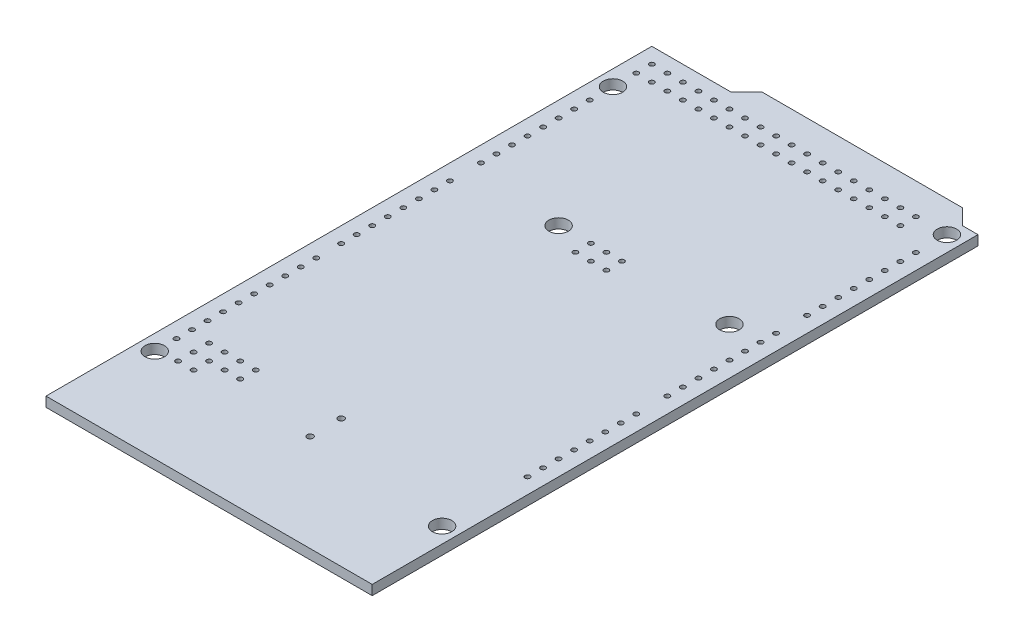
from build123d import *

# Parameters (mm, degrees)
SKETCH1_R           = 1.5875
BOSS_EXTRUDE1_DEPTH = 1.6
SKETCH2_R           = 0.4
CUT_EXTRUDE1_DEPTH  = 1.65
SKETCH3_R           = 0.4
CUT_EXTRUDE2_DEPTH  = 1.65
LPATTERN1_COUNT     = 26
LPATTERN1_PITCH     = 2.54
SKETCH4_R           = 0.4
CUT_EXTRUDE3_DEPTH  = 1.65
LPATTERN2_COUNT     = 10
LPATTERN2_PITCH     = 2.54
LPATTERN3_COUNT     = 17
LPATTERN3_PITCH     = 2.54
SKETCH5_R           = 0.4
SKETCH5_R_2         = 0.5
CUT_EXTRUDE4_DEPTH  = 10
SKETCH7_R           = 0.4
CUT_EXTRUDE6_DEPTH  = 10
LPATTERN4_COUNT     = 18
LPATTERN4_PITCH     = 2.54


with BuildPart() as part:
    # Sketch1 → Boss-Extrude1 (new body)
    with BuildSketch(Plane(origin=(0, 0, 0), x_dir=(1, 0, 0), z_dir=(0, 1, 0))):
        Polygon((0, 0), (-53.34, 0), (-53.34, 99.06), (-40.386, 99.06), (-37.846, 101.6), (-5.08, 101.6), (-2.54, 99.06), (0, 99.06), align=None)
        with Locations((-7.62, 66.04)):
            Circle(SKETCH1_R, mode=Mode.SUBTRACT)
        with Locations((-35.56, 66.04)):
            Circle(SKETCH1_R, mode=Mode.SUBTRACT)
        with Locations((-2.54, 13.97)):
            Circle(SKETCH1_R, mode=Mode.SUBTRACT)
        with Locations((-50.8, 15.24)):
            Circle(SKETCH1_R, mode=Mode.SUBTRACT)
        with Locations((-2.54, 96.52)):
            Circle(SKETCH1_R, mode=Mode.SUBTRACT)
        with Locations((-50.8, 90.17)):
            Circle(SKETCH1_R, mode=Mode.SUBTRACT)
    extrude(amount=-BOSS_EXTRUDE1_DEPTH)

    # Sketch2 → Cut-Extrude1 (cut)
    with BuildSketch(Plane(origin=(0, 0, 0), x_dir=(1, 0, 0), z_dir=(0, 1, 0))):
        with Locations((-2.54, 27.94)):
            Circle(SKETCH2_R)
    cut_extrude1 = extrude(amount=-CUT_EXTRUDE1_DEPTH, mode=Mode.SUBTRACT)

    # Sketch3 → Cut-Extrude2 (cut)
    with BuildSketch(Plane(origin=(0, 0, 0), x_dir=(1, 0, 0), z_dir=(0, 1, 0))):
        with Locations((-50.8, 18.796)):
            Circle(SKETCH3_R)
    cut_extrude2 = extrude(amount=-CUT_EXTRUDE2_DEPTH, mode=Mode.SUBTRACT)

    # LPattern1: Cut-Extrude1 ×26, 2 skipped
    with Locations(*[(0, 0, -i * LPATTERN1_PITCH) for i in range(1, LPATTERN1_COUNT) if i not in (8, 17)]):
        add(cut_extrude1, mode=Mode.SUBTRACT)

    # Sketch4 → Cut-Extrude3 (cut)
    with BuildSketch(Plane(origin=(0, 0, 0), x_dir=(1, 0, 0), z_dir=(0, 1, 0))):
        with Locations((-50.8, 45.72)):
            Circle(SKETCH4_R)
    cut_extrude3 = extrude(amount=-CUT_EXTRUDE3_DEPTH, mode=Mode.SUBTRACT)

    # LPattern2: Cut-Extrude2 ×10
    with Locations(*[(0, 0, -i * LPATTERN2_PITCH) for i in range(1, LPATTERN2_COUNT)]):
        add(cut_extrude2, mode=Mode.SUBTRACT)

    # LPattern3: Cut-Extrude3 ×17, 1 skipped
    with Locations(*[(0, 0, -i * LPATTERN3_PITCH) for i in range(1, LPATTERN3_COUNT) if i not in (8,)]):
        add(cut_extrude3, mode=Mode.SUBTRACT)

    # Sketch5 → Cut-Extrude4 (cut)
    with BuildSketch(Plane(origin=(0, 0, 0), x_dir=(1, 0, 0), z_dir=(0, 1, 0))):
        with Locations((-30.43, 66.18)):
            Circle(SKETCH5_R)
        with Locations((-27.89, 66.18)):
            Circle(SKETCH5_R)
        with Locations((-25.35, 66.18)):
            Circle(SKETCH5_R)
        with Locations((-25.35, 63.64)):
            Circle(SKETCH5_R)
        with Locations((-27.89, 63.64)):
            Circle(SKETCH5_R)
        with Locations((-30.43, 63.64)):
            Circle(SKETCH5_R)
        with Locations((-47.498, 15.748)):
            Circle(SKETCH5_R)
        with Locations((-47.498, 18.288)):
            Circle(SKETCH5_R)
        with Locations((-47.498, 20.828)):
            Circle(SKETCH5_R)
        with Locations((-44.958, 20.828)):
            Circle(SKETCH5_R)
        with Locations((-44.958, 18.288)):
            Circle(SKETCH5_R)
        with Locations((-44.958, 15.748)):
            Circle(SKETCH5_R)
        with Locations((-42.418, 18.288)):
            Circle(SKETCH5_R)
        with Locations((-42.418, 20.828)):
            Circle(SKETCH5_R)
        with Locations((-39.878, 20.828)):
            Circle(SKETCH5_R)
        with Locations((-39.878, 18.288)):
            Circle(SKETCH5_R)
        with Locations((-26.035, 20.955)):
            Circle(SKETCH5_R_2)
        with Locations((-26.035, 15.875)):
            Circle(SKETCH5_R_2)
    extrude(amount=-CUT_EXTRUDE4_DEPTH, mode=Mode.SUBTRACT)

    # Sketch7 → Cut-Extrude6 (cut)
    with BuildSketch(Plane(origin=(0, 0, 0), x_dir=(1, 0, 0), z_dir=(0, 1, 0))):
        with Locations((-50.8, 96.52)):
            Circle(SKETCH7_R)
        with Locations((-50.8, 93.98)):
            Circle(SKETCH7_R)
    cut_extrude6 = extrude(amount=-CUT_EXTRUDE6_DEPTH, mode=Mode.SUBTRACT)

    # LPattern4: Cut-Extrude6 ×18
    with Locations(*[(i * LPATTERN4_PITCH, 0, 0) for i in range(1, LPATTERN4_COUNT)]):
        add(cut_extrude6, mode=Mode.SUBTRACT)


solid = part.part
